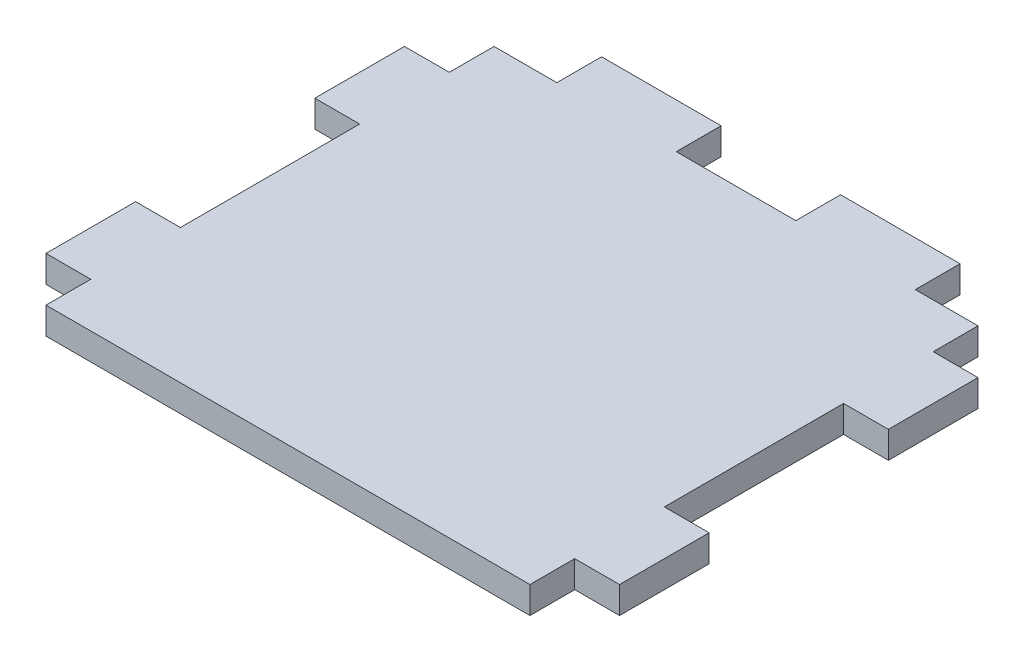
from build123d import *

# Parameters (mm, degrees)
BOSS_EXTRUDE1_DEPTH = 4.5


with BuildPart() as part:
    # Sketch1 → Boss-Extrude1 (new body)
    with BuildSketch(Plane(origin=(0, 0, 0), x_dir=(1, 0, 0), z_dir=(0, 1, 0))):
        Polygon((-30, 37.5), (-40.5, 37.5), (-40.5, 30), (-48, 30), (-48, 15), (-40.5, 15), (-40.5, -15), (-48, -15), (-48, -30), (-40.5, -30), (-40.5, -37.5), (40.5, -37.5), (40.5, -30), (48, -30), (48, -15), (40.5, -15), (40.5, 15), (48, 15), (48, 30), (40.5, 30), (40.5, 37.5), (30, 37.5), (30, 45), (10, 45), (10, 37.5), (-10, 37.5), (-10, 45), (-30, 45), align=None)
    extrude(amount=BOSS_EXTRUDE1_DEPTH)


solid = part.part
